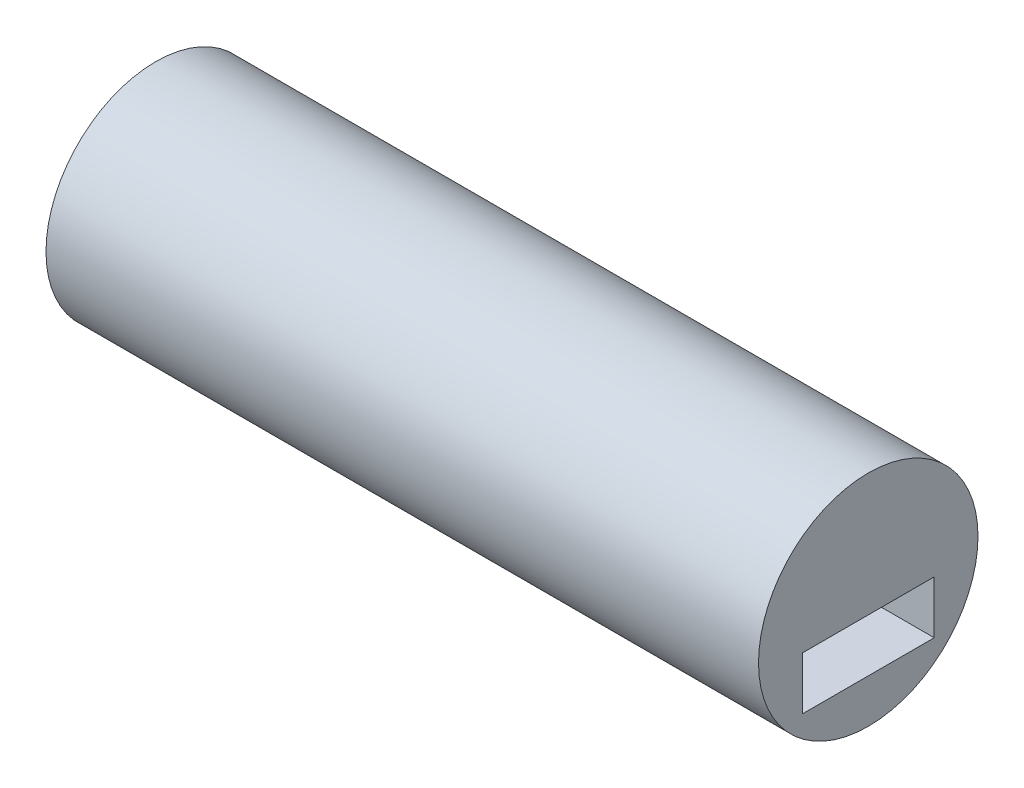
from build123d import *

# Parameters (mm, degrees)
SKETCH1_R           = 93.17284
SKETCH1_W           = 100
SKETCH1_H           = 40
BOSS_EXTRUDE1_DEPTH = 540
SKETCH2_OUTSIDE_W   = 308.52
SKETCH2_OUTSIDE_H   = 308.52
SKETCH2_OUTSIDE_R   = 83.17284
CUT_EXTRUDE2_DEPTH  = 541


with BuildPart() as part:
    # Sketch1 → Boss-Extrude1 (new body)
    with BuildSketch(Plane(origin=(0, 0, 0), x_dir=(0, 0, -1), z_dir=(1, 0, 0))):
        Circle(SKETCH1_R)
        with Locations((0, -30)):
            Rectangle(SKETCH1_W, SKETCH1_H, mode=Mode.SUBTRACT)
    extrude(amount=BOSS_EXTRUDE1_DEPTH)

    # Sketch2 outside → Cut-Extrude2 (cut, through all)
    with BuildSketch(Plane(origin=(540, 0, 0), x_dir=(0, 0, -1), z_dir=(1, 0, 0))):
        Rectangle(SKETCH2_OUTSIDE_W, SKETCH2_OUTSIDE_H)
        Circle(SKETCH2_OUTSIDE_R, mode=Mode.SUBTRACT)
    extrude(amount=-CUT_EXTRUDE2_DEPTH, mode=Mode.SUBTRACT)


solid = part.part
